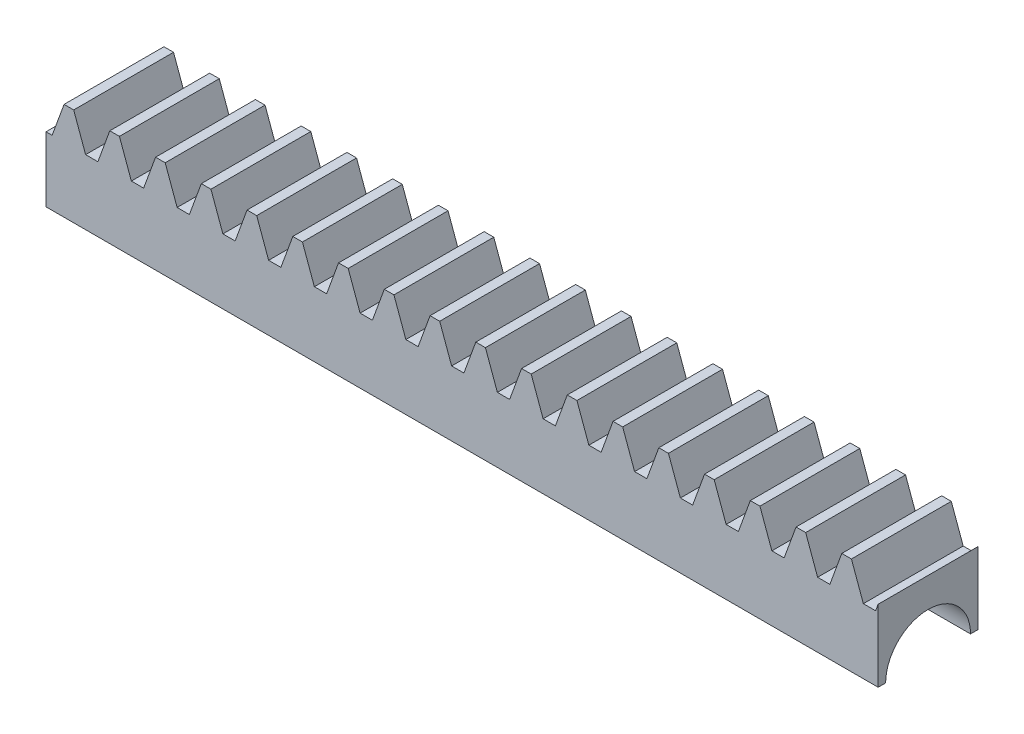
from build123d import *

# Parameters (mm, degrees)
BLANKSKE_W         = 100
BLANKSKE_H         = 11.75
BLANK_DEPTH        = 12
TOOTHCUTSIM_DEPTH  = 102.400505423
TEETHCUTS_COUNT    = 19
TEETHCUTS_PITCH    = 5.497787138
SKETCH1_R          = 5.1
CUT_EXTRUDE1_DEPTH = 102.400505423


with BuildPart() as part:
    # BlankSke → Blank (new body)
    with BuildSketch(Plane.XY):
        with Locations((50, 5.875)):
            Rectangle(BLANKSKE_W, BLANKSKE_H)
    extrude(amount=-BLANK_DEPTH)

    # TooCutSkeSim → ToothCutSim (cut, through all)
    with BuildSketch(Plane.XY):
        Polygon((0.737261897, 7.8125), (-0.737261897, 7.8125), (-2.179639538, 11.7754), (2.179639538, 11.7754), align=None)
    toothcutsim = extrude(amount=-TOOTHCUTSIM_DEPTH, mode=Mode.SUBTRACT)

    # TeethCuts: ToothCutSim ×19
    with Locations(*[(i * TEETHCUTS_PITCH, 0, 0) for i in range(1, TEETHCUTS_COUNT)]):
        add(toothcutsim, mode=Mode.SUBTRACT)

    # Sketch1 → Cut-Extrude1 (cut, through all)
    with BuildSketch(Plane(origin=(100, 0, 0), x_dir=(0, 0, -1), z_dir=(1, 0, 0))):
        with Locations((6, 0)):
            Circle(SKETCH1_R)
    extrude(amount=-CUT_EXTRUDE1_DEPTH, mode=Mode.SUBTRACT)


solid = part.part
